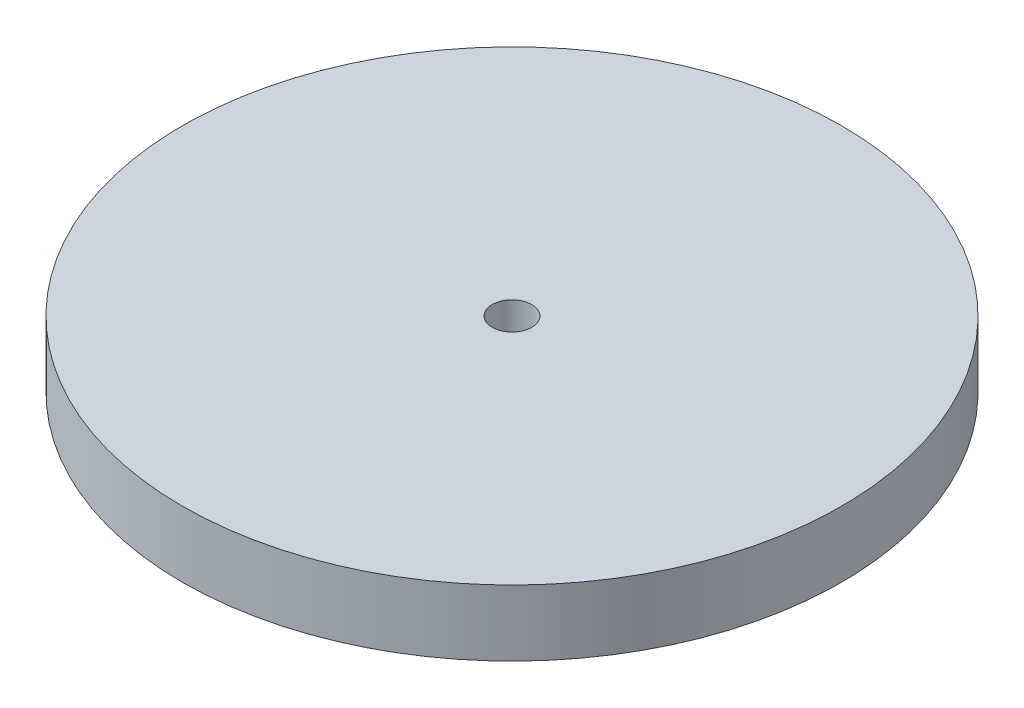
from build123d import *

# Parameters (mm, degrees)
SKETCH1_R           = 50
SKETCH1_R_2         = 3
BOSS_EXTRUDE1_DEPTH = 10


with BuildPart() as part:
    # Sketch1 → Boss-Extrude1 (new body)
    with BuildSketch(Plane(origin=(0, 0, 0), x_dir=(1, 0, 0), z_dir=(0, 1, 0))):
        Circle(SKETCH1_R)
        Circle(SKETCH1_R_2, mode=Mode.SUBTRACT)
    extrude(amount=BOSS_EXTRUDE1_DEPTH)


solid = part.part
